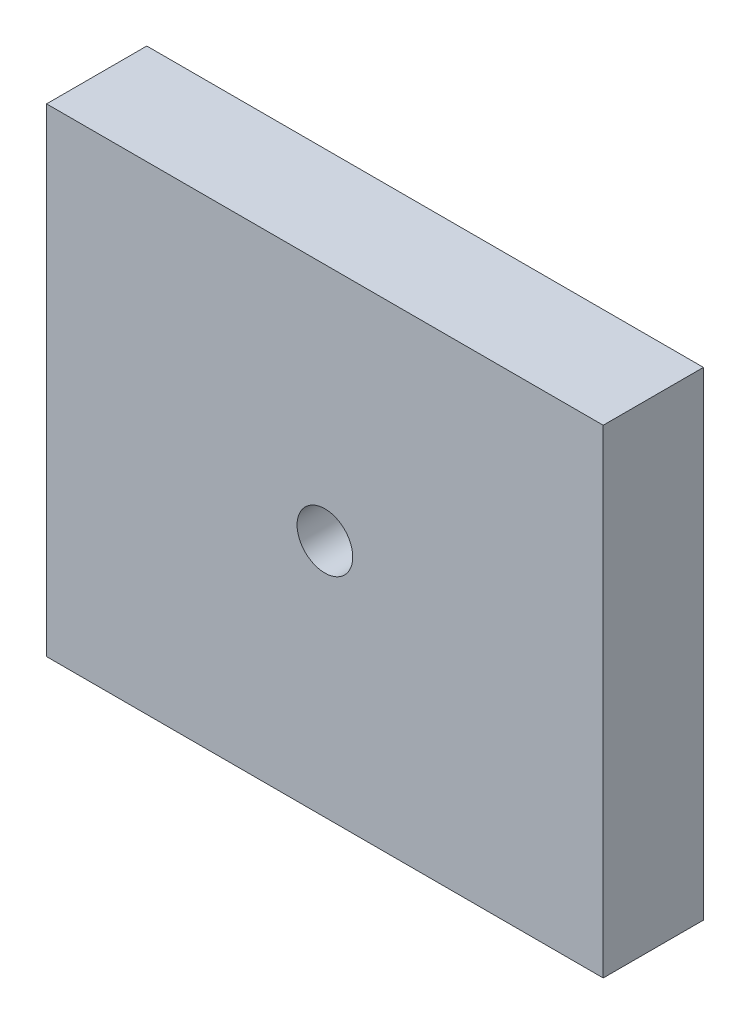
from build123d import *

# Parameters (mm, degrees)
ESQUISSE3_W                  = 50
ESQUISSE3_H                  = 43
BOSS_EXTRU_1_DEPTH           = 9
ESQUISSE4_R                  = 2.5
ENL_V_MAT_EXTRU_1_DEPTH      = 1
ENL_V_MAT_EXTRU_1_DEPTH_BACK = 10


with BuildPart() as part:
    # Esquisse3 → Boss.-Extru.1 (new body)
    with BuildSketch(Plane.XY):
        with Locations((25, 21.5)):
            Rectangle(ESQUISSE3_W, ESQUISSE3_H)
    extrude(amount=BOSS_EXTRU_1_DEPTH)

    # Esquisse4 → Enlèv. mat.-Extru.1 (cut, two sides)
    with BuildSketch(Plane.XY.offset(9)) as enl_v_mat_extru_1_sk:
        with Locations((25, 21.5)):
            Circle(ESQUISSE4_R)
    extrude(amount=ENL_V_MAT_EXTRU_1_DEPTH, mode=Mode.SUBTRACT)
    extrude(enl_v_mat_extru_1_sk.sketch, amount=-ENL_V_MAT_EXTRU_1_DEPTH_BACK, mode=Mode.SUBTRACT)


solid = part.part
